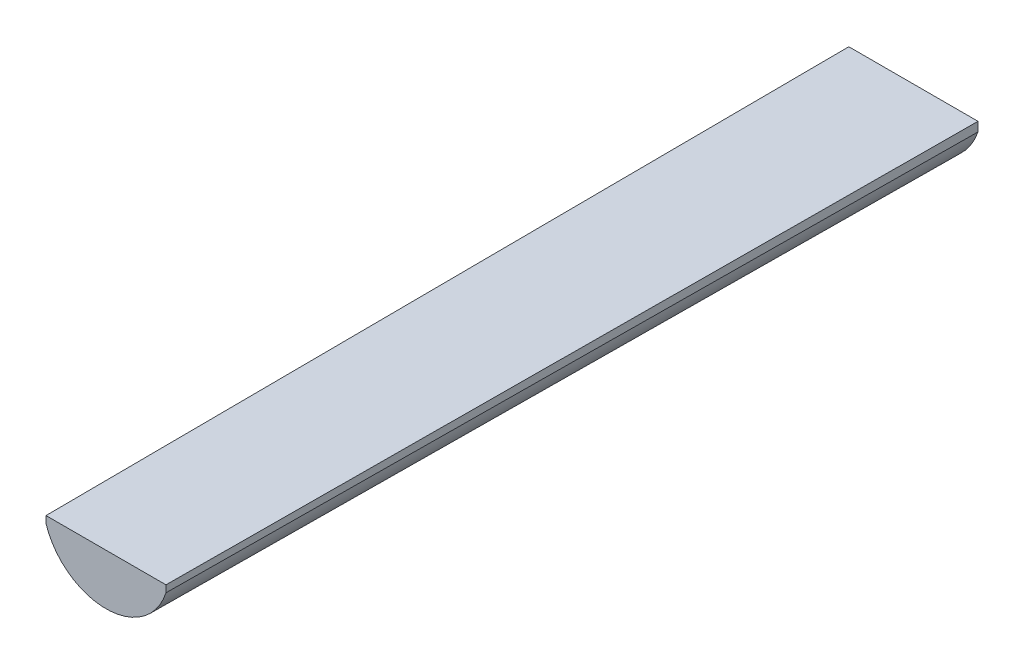
from build123d import *


with BuildPart() as part:
    # Skica2 → Spojit profily1 section 0
    with BuildSketch(Plane.XY):
        with BuildLine():
            Line((-26, 0), (26, 0))
            Line((26, 0), (26, -3))
            ThreePointArc((26, -3), (0, -22), (-26, -3))
            Line((-26, -3), (-26, 0))
        make_face()
    # Skica3 → Spojit profily1 section 1
    with BuildSketch(Plane.XY.offset(-350)):
        with BuildLine():
            Line((28, 0), (-28, 0))
            Line((-28, 0), (-28, -4))
            ThreePointArc((-28, -4), (0, -24), (28, -4))
            Line((28, -4), (28, 0))
        make_face()
    loft()


solid = part.part
